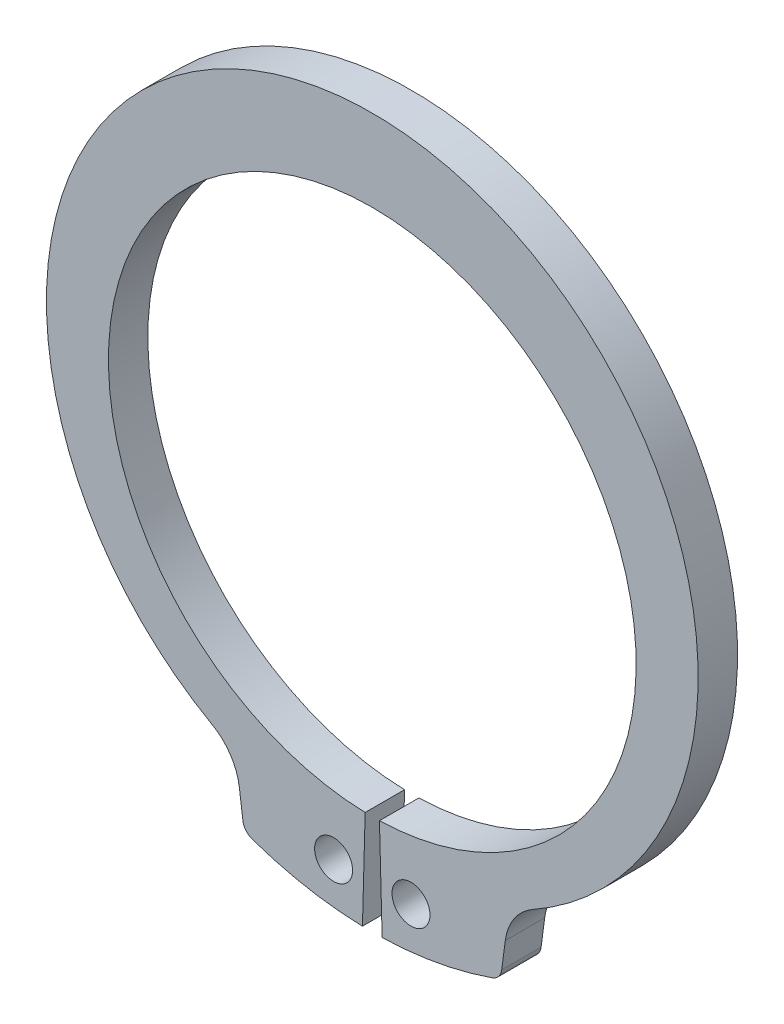
from build123d import *

# Parameters (mm, degrees)
BODYSKE_R  = 1.35
BODY_DEPTH = 2.8


with BuildPart() as part:
    # BodySke → Body (new body)
    with BuildSketch(Plane.XY):
        with BuildLine():
            Line((0.507736944, -18.743124158), (0.7, -25.840520506))
            ThreePointArc((0.7, -25.840520506), (4.672397443, -25.424224711), (8.533245372, -24.400947183))
            ThreePointArc((8.533245372, -24.400947183), (8.979049185, -24.087846983), (9.194584029, -23.587529577))
            Line((9.194584029, -23.587529577), (9.449900977, -21.648204824))
            ThreePointArc((9.449900977, -21.648204824), (10.083365414, -19.976593629), (11.396331128, -18.763464529))
            ThreePointArc((11.396331128, -18.763464529), (0, 24.55), (-11.396331128, -18.763464529))
            ThreePointArc((-11.396331128, -18.763464529), (-10.083365414, -19.976593629), (-9.449900977, -21.648204824))
            Line((-9.449900977, -21.648204824), (-9.194584029, -23.587529577))
            ThreePointArc((-9.194584029, -23.587529577), (-8.979049185, -24.087846983), (-8.533245372, -24.400947183))
            ThreePointArc((-8.533245372, -24.400947183), (-4.672397443, -25.424224711), (-0.7, -25.840520506))
            Line((-0.7, -25.840520506), (-0.507736944, -18.743124158))
            ThreePointArc((-0.507736944, -18.743124158), (0, 18.75), (0.507736944, -18.743124158))
        make_face()
        with Locations((2.75, -22.759462318)):
            Circle(BODYSKE_R, mode=Mode.SUBTRACT)
        with Locations((-2.75, -22.759462318)):
            Circle(BODYSKE_R, mode=Mode.SUBTRACT)
    extrude(amount=-BODY_DEPTH)


solid = part.part
